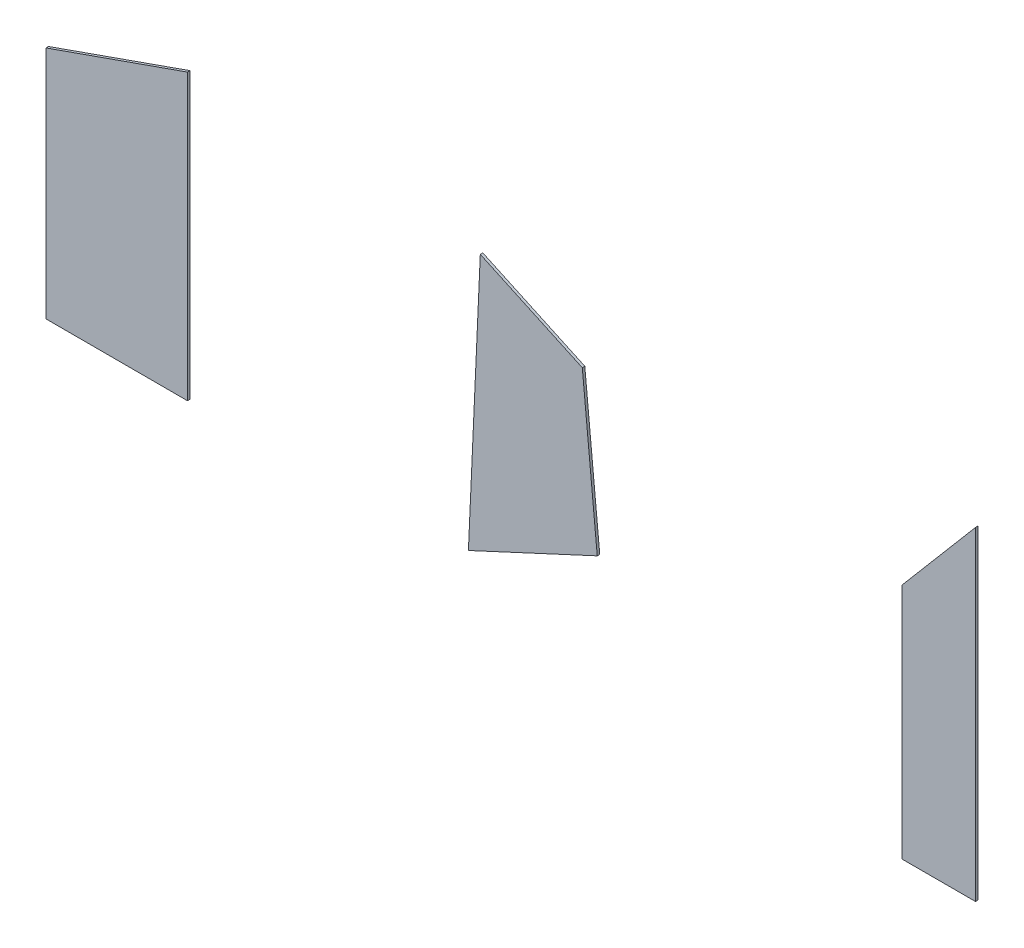
from build123d import *

# Parameters (mm, degrees)
Y_KSEKLIK_EKSTR_ZYON1_DEPTH   = 12
Y_KSEKLIK_EKSTR_ZYON1_2_DEPTH = 12
Y_KSEKLIK_EKSTR_ZYON1_3_DEPTH = 12


with BuildPart() as part:
    # Çizim1 → Yükseklik-Ekstrüzyon1 (new body)
    with BuildSketch(Plane.XY):
        Polygon((-11544.763432538, -24265.175463113), (-11544.775691722, -25628.835401716), (-12222.546966622, -25628.154435718), (-12222.526758536, -24503.905779923), align=None)
    extrude(amount=Y_KSEKLIK_EKSTR_ZYON1_DEPTH)


with BuildPart() as body_2:
    # Çizim1 → Y_kseklik-Ekstr_zyon1 2 (new body)
    with BuildSketch(Plane.XY):
        Polygon((-8121.566339207, -24681.832172443), (-8121.59447703, -25818.823497743), (-7769.613636026, -25818.845017714), (-7769.560705178, -24266.909097047), align=None)
    extrude(amount=Y_KSEKLIK_EKSTR_ZYON1_2_DEPTH)


with BuildPart() as body_3:
    # Çizim1 → Y_kseklik-Ekstr_zyon1 3 (new body)
    with BuildSketch(Plane.XY):
        Polygon((-10141.898890802, -24320.024195408), (-10198.876287928, -25577.160508614), (-9581.692257619, -25290.850614754), (-9653.250878476, -24545.847392263), align=None)
    extrude(amount=Y_KSEKLIK_EKSTR_ZYON1_3_DEPTH)


solid = Compound([part.part, body_2.part, body_3.part])
